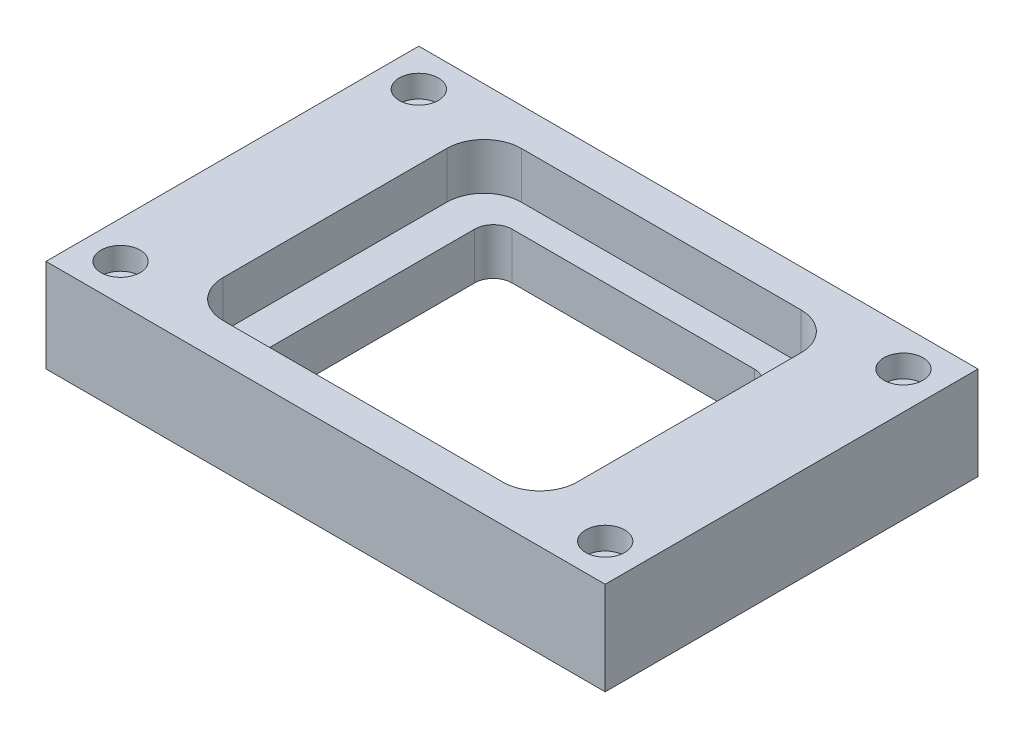
from build123d import *

# Parameters (mm, degrees)
CROQUIS1_W                   = 300
CROQUIS1_H                   = 200
SALIENTE_EXTRUIR1_DEPTH      = 50
TALADRO1_D                   = 12
TALADRO1_DEPTH               = 50.801082666
TALADRO1_CBORE_D             = 21
TALADRO1_CBORE_DEPTH         = 12
SIMETR_A2_COPY_1_D           = 12
SIMETR_A2_COPY_1_DEPTH       = 50.801082666
SIMETR_A2_COPY_1_CBORE_D     = 21
SIMETR_A2_COPY_1_CBORE_DEPTH = 12
SIMETR_A2_COPY_2_D           = 12
SIMETR_A2_COPY_2_DEPTH       = 50.801082666
SIMETR_A2_COPY_2_CBORE_D     = 21
SIMETR_A2_COPY_2_CBORE_DEPTH = 12
CORTAR_EXTRUIR1_DEPTH        = 25
CORTAR_EXTRUIR2_DEPTH        = 51


with BuildPart() as part:
    # Croquis1 → Saliente-Extruir1 (new body)
    with BuildSketch(Plane(origin=(0, 0, 0), x_dir=(1, 0, 0), z_dir=(0, 1, 0))):
        Rectangle(CROQUIS1_W, CROQUIS1_H)
    extrude(amount=SALIENTE_EXTRUIR1_DEPTH)

    # Taladro1
    with Locations(Plane(origin=(0, 50, 0), x_dir=(1, 0, 0), z_dir=(0, 1, 0))):
        with Locations((-130, 80)):
            taladro1 = CounterBoreHole(TALADRO1_D / 2, TALADRO1_CBORE_D / 2, TALADRO1_CBORE_DEPTH, depth=TALADRO1_DEPTH)

    # Simetría1: Taladro1 across plane
    add(taladro1.mirror(Plane(origin=(0, 0, 0), x_dir=(0, 0, 1), z_dir=(1, 0, 0))), mode=Mode.SUBTRACT)

    # Simetría2 copy 1
    with Locations(Plane(origin=(0, 50, 0), x_dir=(-1, 0, 0), z_dir=(0, 1, 0))):
        with Locations((-130, 80)):
            CounterBoreHole(SIMETR_A2_COPY_1_D / 2, SIMETR_A2_COPY_1_CBORE_D / 2, SIMETR_A2_COPY_1_CBORE_DEPTH, depth=SIMETR_A2_COPY_1_DEPTH)

    # Simetría2 copy 2
    with Locations(Plane(origin=(0, 50, 0), x_dir=(1, 0, 0), z_dir=(0, 1, 0))):
        with Locations((-130, -80)):
            CounterBoreHole(SIMETR_A2_COPY_2_D / 2, SIMETR_A2_COPY_2_CBORE_D / 2, SIMETR_A2_COPY_2_CBORE_DEPTH, depth=SIMETR_A2_COPY_2_DEPTH)

    # Croquis4 → Cortar-Extruir1 (cut)
    with BuildSketch(Plane(origin=(0, 50, 0), x_dir=(1, 0, 0), z_dir=(0, 1, 0))):
        with BuildLine():
            Line((-75, 80), (75, 80))
            ThreePointArc((75, 80), (89.142135624, 74.142135624), (95, 60))
            Line((95, 60), (95, -60))
            ThreePointArc((95, -60), (89.142135624, -74.142135624), (75, -80))
            Line((75, -80), (-75, -80))
            ThreePointArc((-75, -80), (-89.142135624, -74.142135624), (-95, -60))
            Line((-95, -60), (-95, 60))
            ThreePointArc((-95, 60), (-89.142135624, 74.142135624), (-75, 80))
        make_face()
        with BuildLine():
            Line((-65, 65), (65, 65))
            ThreePointArc((65, 65), (72.071067812, 62.071067812), (75, 55))
            Line((75, 55), (75, -55))
            ThreePointArc((75, -55), (72.071067812, -62.071067812), (65, -65))
            Line((65, -65), (-65, -65))
            ThreePointArc((-65, -65), (-72.071067812, -62.071067812), (-75, -55))
            Line((-75, -55), (-75, 55))
            ThreePointArc((-75, 55), (-72.071067812, 62.071067812), (-65, 65))
        make_face(mode=Mode.SUBTRACT)
    extrude(amount=-CORTAR_EXTRUIR1_DEPTH, mode=Mode.SUBTRACT)

    # Croquis4_2 → Cortar-Extruir2 (cut)
    with BuildSketch(Plane(origin=(0, 50, 0), x_dir=(1, 0, 0), z_dir=(0, 1, 0))):
        with BuildLine():
            Line((65, 65), (-65, 65))
            ThreePointArc((-65, 65), (-72.071067812, 62.071067812), (-75, 55))
            Line((-75, 55), (-75, -55))
            ThreePointArc((-75, -55), (-72.071067812, -62.071067812), (-65, -65))
            Line((-65, -65), (65, -65))
            ThreePointArc((65, -65), (72.071067812, -62.071067812), (75, -55))
            Line((75, -55), (75, 55))
            ThreePointArc((75, 55), (72.071067812, 62.071067812), (65, 65))
        make_face()
    extrude(amount=-CORTAR_EXTRUIR2_DEPTH, mode=Mode.SUBTRACT)


solid = part.part
